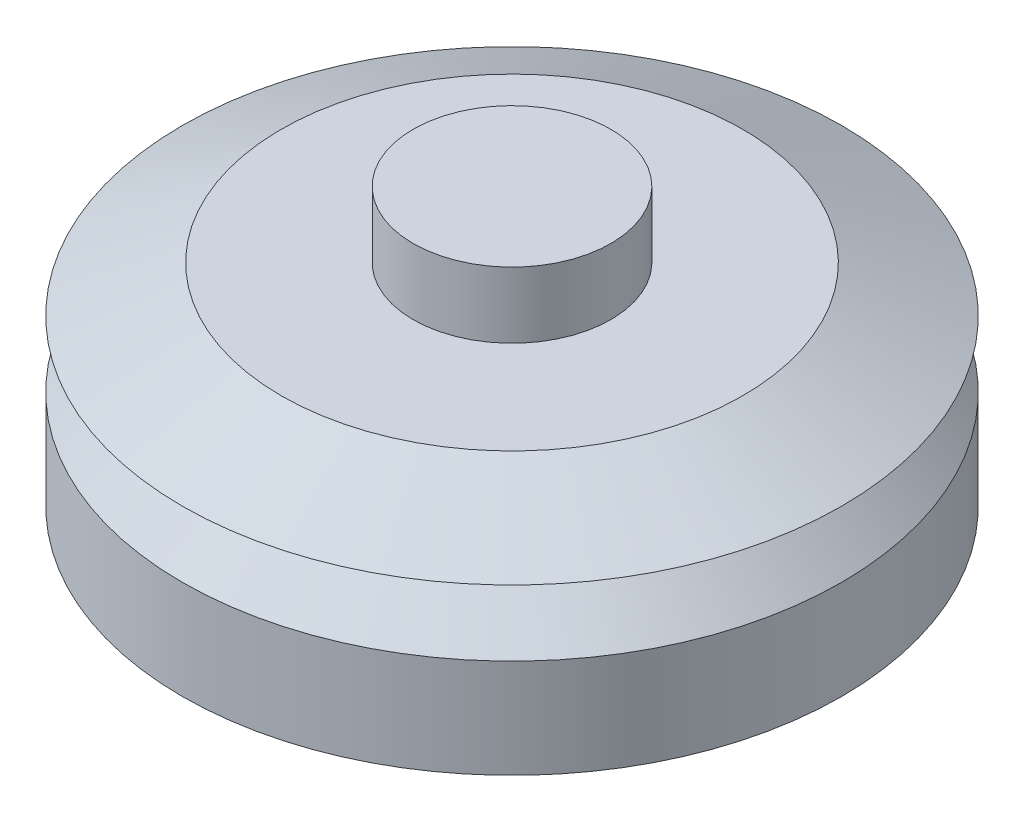
from build123d import *

# Parameters (mm, degrees)
SKETCH1_R           = 50
BOSS_EXTRUDE1_DEPTH = 25
CHAMFER1_SIZE       = 10
SKETCH7_R           = 50
SKETCH8_R           = 35
SKETCH9_R           = 15
BOSS_EXTRUDE5_DEPTH = 10


with BuildPart() as part:
    # Sketch1 → Boss-Extrude1 (new body)
    with BuildSketch(Plane(origin=(0, 0, 0), x_dir=(1, 0, 0), z_dir=(0, 1, 0))):
        Circle(SKETCH1_R)
    extrude(amount=BOSS_EXTRUDE1_DEPTH)

    # Chamfer1
    chamfer1_edges = [part.edges().sort_by_distance(p)[0] for p in [
        (-50, 25, 0),
    ]]
    chamfer(chamfer1_edges, length=CHAMFER1_SIZE)

    # Sketch7 → Loft1 section 0
    with BuildSketch(Plane(origin=(0, 25, 0), x_dir=(1, 0, 0), z_dir=(0, 1, 0))):
        Circle(SKETCH7_R)
    # Sketch8 → Loft1 section 1
    with BuildSketch(Plane(origin=(0, 32, 0), x_dir=(1, 0, 0), z_dir=(0, 1, 0))):
        Circle(SKETCH8_R)
    loft()

    # Sketch9 → Boss-Extrude5 (add)
    with BuildSketch(Plane(origin=(0, 32, 0), x_dir=(1, 0, 0), z_dir=(0, 1, 0))):
        Circle(SKETCH9_R)
    extrude(amount=BOSS_EXTRUDE5_DEPTH)


solid = part.part
